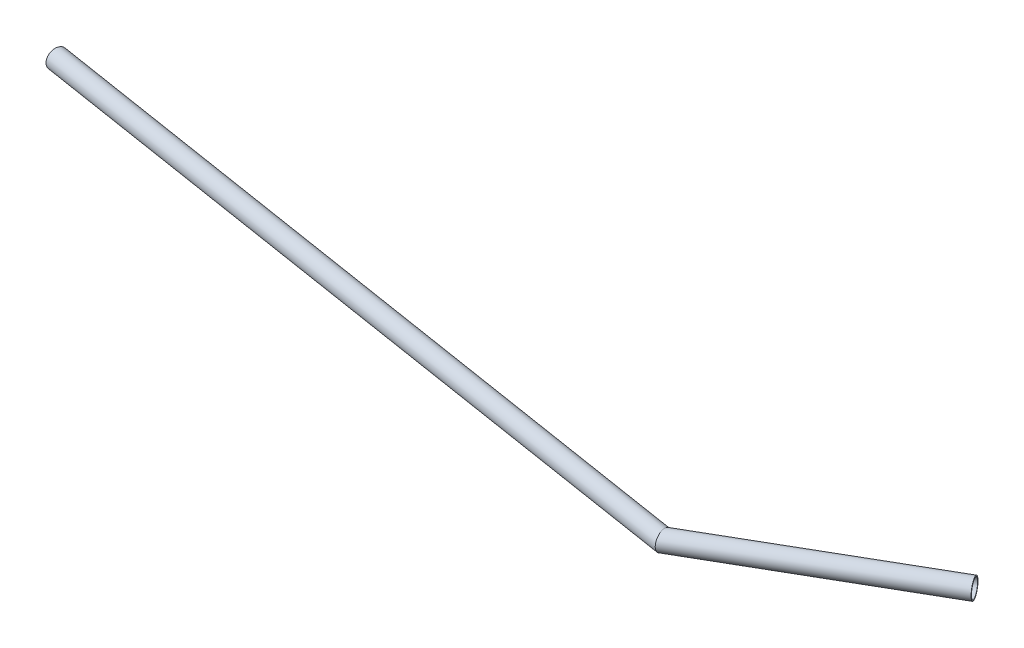
from build123d import *

# Parameters (mm, degrees)
SKETCH2_R   = 9.525
SKETCH2_R_2 = 8.525


with BuildPart() as part:
    # Sweep-Thin1: sweep along a path in Sketch1
    with BuildLine(Plane(origin=(0, 0, 0), x_dir=(1, 0, 0), z_dir=(0, 1, 0))) as sweep_thin1_path:
        Line((465, 0), (265, -115.470053838))
        Line((265, -115.470053838), (-465, 0))
    # Sketch2 → Sweep-Thin1 (sweep)
    with BuildSketch(Plane(origin=(-465, 0, 0), x_dir=(0.156235697, 0, -0.987719802), z_dir=(0.987719802, 0, 0.156235697))):
        Circle(SKETCH2_R)
        Circle(SKETCH2_R_2, mode=Mode.SUBTRACT)
    sweep(path=sweep_thin1_path.line, transition=Transition.RIGHT)


solid = part.part
